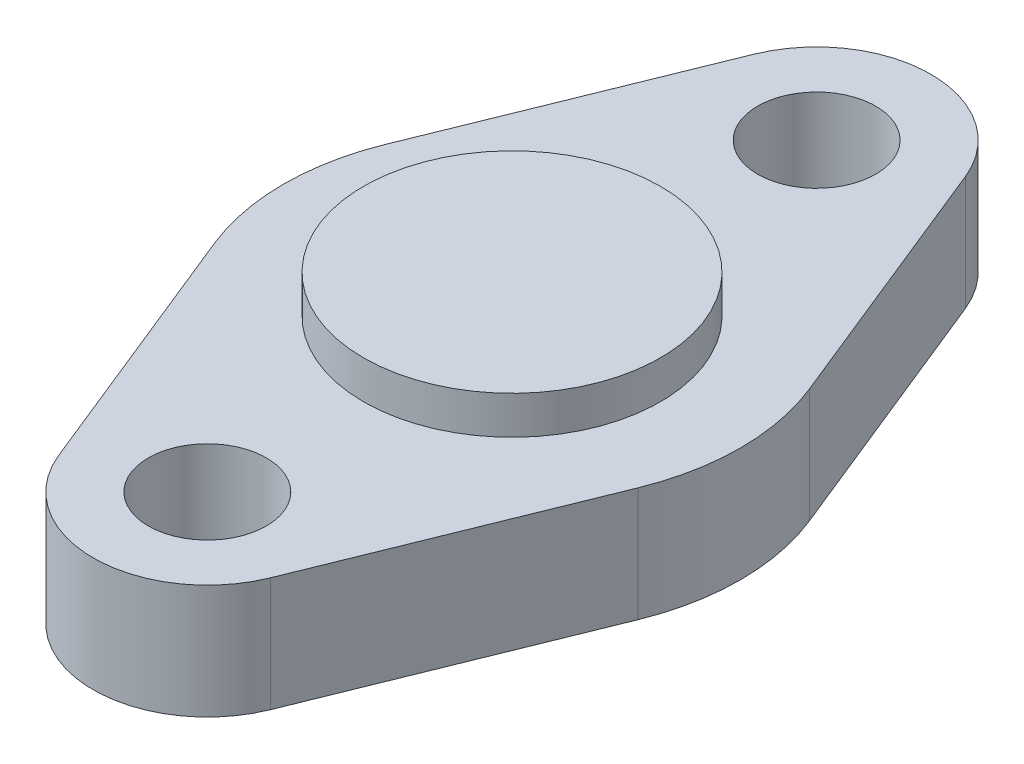
from build123d import *

# Parameters (mm, degrees)
CROQUIS2_R              = 1.55
SALIENTE_EXTRUIR1_DEPTH = 3
CROQUIS3_R              = 3.9
SALIENTE_EXTRUIR2_DEPTH = 1


with BuildPart() as part:
    # Croquis2 → Saliente-Extruir1 (new body)
    with BuildSketch(Plane(origin=(0, 0, 0), x_dir=(1, 0, 0), z_dir=(0, 1, 0))):
        with BuildLine():
            Line((2.781074433, 17.125), (5.562148865, 10.25))
            ThreePointArc((5.562148865, 10.25), (6, 8), (5.562148865, 5.75))
            Line((5.562148865, 5.75), (2.781074433, -1.125))
            ThreePointArc((2.781074433, -1.125), (0, -3), (-2.781074433, -1.125))
            Line((-2.781074433, -1.125), (-5.562148865, 5.75))
            ThreePointArc((-5.562148865, 5.75), (-6, 8), (-5.562148865, 10.25))
            Line((-5.562148865, 10.25), (-2.781074433, 17.125))
            ThreePointArc((-2.781074433, 17.125), (0, 19), (2.781074433, 17.125))
        make_face()
        with Locations((0, 16)):
            Circle(CROQUIS2_R, mode=Mode.SUBTRACT)
        Circle(CROQUIS2_R, mode=Mode.SUBTRACT)
    extrude(amount=SALIENTE_EXTRUIR1_DEPTH)

    # Croquis3 → Saliente-Extruir2 (add)
    with BuildSketch(Plane(origin=(0, 3, 0), x_dir=(1, 0, 0), z_dir=(0, 1, 0))):
        with Locations((0, 8)):
            Circle(CROQUIS3_R)
    extrude(amount=SALIENTE_EXTRUIR2_DEPTH)


solid = part.part
